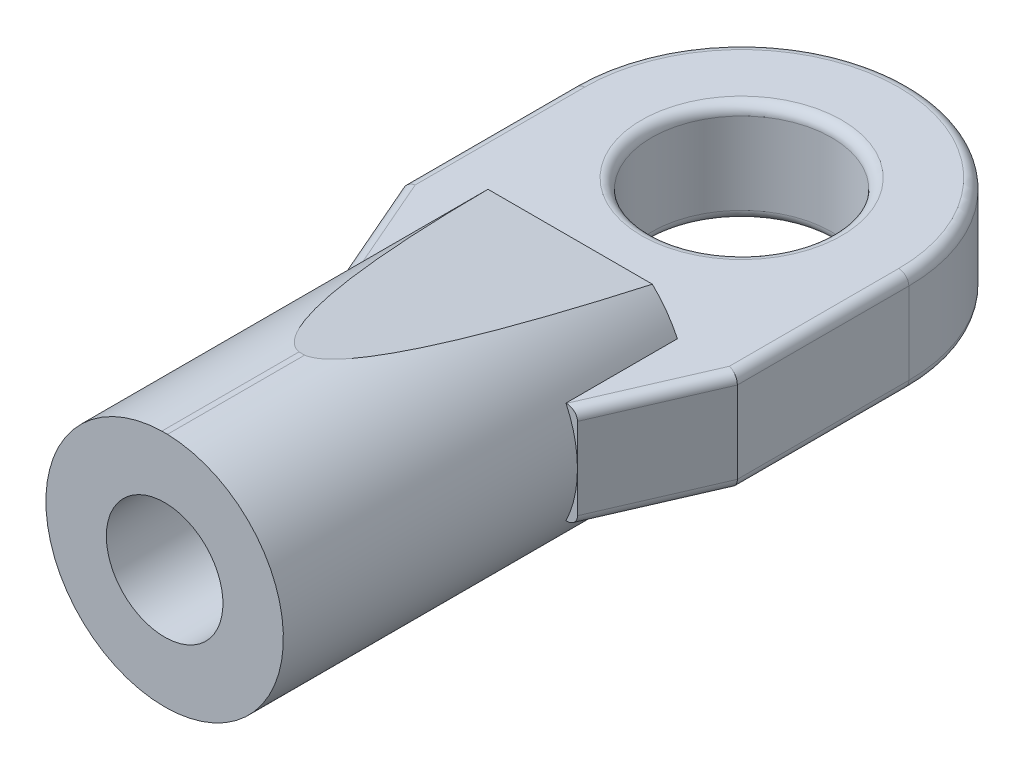
from build123d import *

# Parameters (mm, degrees)
CUT_EXTRUDE1_START  = -2.434961
SKETCH2_OUTSIDE_W   = 17.134
SKETCH2_OUTSIDE_H   = 12.156
CUT_EXTRUDE1_DEPTH  = 4.869922
SKETCH7_R           = 2.667
BOSS_EXTRUDE2_DEPTH = 1.51
FILLET1_R           = 0.3
FILLET2_R           = 0.3
FILLET3_R           = 0.3
FILLET4_R           = 0.3


with BuildPart() as part:
    # Sketch1 → Revolve1 (revolve)
    with BuildSketch(Plane(origin=(0, 0, 0), x_dir=(1, 0, 0), z_dir=(0, 1, 0))):
        Polygon((-3.5179, -17.0942), (-1.7272, -17.0942), (-1.7272, -5.6642), (0, -5.6642), (0, -5.08), (-3.5179, -5.08), (-3.5179, -8.382), align=None)
    revolve(axis=Axis((0, 0, 0), (0, 0, 1)))

    # Sketch2 outside → Cut-Extrude1 (cut)
    with BuildSketch(Plane(origin=(0, 0, 0), x_dir=(0, 0, -1), z_dir=(1, 0, 0)).offset(CUT_EXTRUDE1_START)):
        with Locations((-11.087, 0)):
            Rectangle(SKETCH2_OUTSIDE_W, SKETCH2_OUTSIDE_H)
        Polygon((-17.0942, -3.51888695), (-17.0942, 3.51691305), (-13.0302, 3.51691305), (-5.08, 2.53901305), (-5.08, -2.54098695), (-13.0302, -3.51888695), align=None, mode=Mode.SUBTRACT)
    extrude(amount=CUT_EXTRUDE1_DEPTH, mode=Mode.SUBTRACT)

    # Sketch7 → Boss-Extrude2 (add, symmetric)
    with BuildSketch(Plane(origin=(0, 0, 0), x_dir=(1, 0, 0), z_dir=(0, 1, 0))):
        with BuildLine():
            Line((-4.953, 0), (-4.953, -5.08))
            Line((-4.953, -5.08), (-3.5179, -8.382))
            Line((-3.5179, -8.382), (3.5179, -8.382))
            Line((3.5179, -8.382), (4.953, -5.08))
            Line((4.953, -5.08), (4.953, 0))
            ThreePointArc((4.953, 0), (0, 4.953), (-4.953, 0))
        make_face()
        with Locations(Location((0, 0, 0), (0, 0, 90))):
            Circle(SKETCH7_R, mode=Mode.SUBTRACT)
    extrude(amount=BOSS_EXTRUDE2_DEPTH, both=True)

    # Fillet1
    fillet1_edges = [part.edges().sort_by_distance(p)[0] for p in [
        (0, -1.51, -4.953),
        (-4.953, -1.51, 2.54),
        (-4.23545, -1.51, 6.731),
        (4.23545, -1.51, 6.731),
        (4.953, -1.51, 2.54),
    ]]
    fillet(fillet1_edges, radius=FILLET1_R)

    # Fillet2
    fillet2_edges = [part.edges().sort_by_distance(p)[0] for p in [
        (4.23545, 1.51, 6.731),
        (4.953, 1.51, 2.54),
        (0, 1.51, -4.953),
        (-4.953, 1.51, 2.54),
        (-4.23545, 1.51, 6.731),
    ]]
    fillet(fillet2_edges, radius=FILLET2_R)

    # Fillet3
    fillet3_edges = [part.edges().sort_by_distance(p)[0] for p in [
        (0, 1.51, 2.667),
    ]]
    fillet(fillet3_edges, radius=FILLET3_R)

    # Fillet4
    fillet4_edges = [part.edges().sort_by_distance(p)[0] for p in [
        (0, -1.51, 2.667),
    ]]
    fillet(fillet4_edges, radius=FILLET4_R)


solid = part.part
